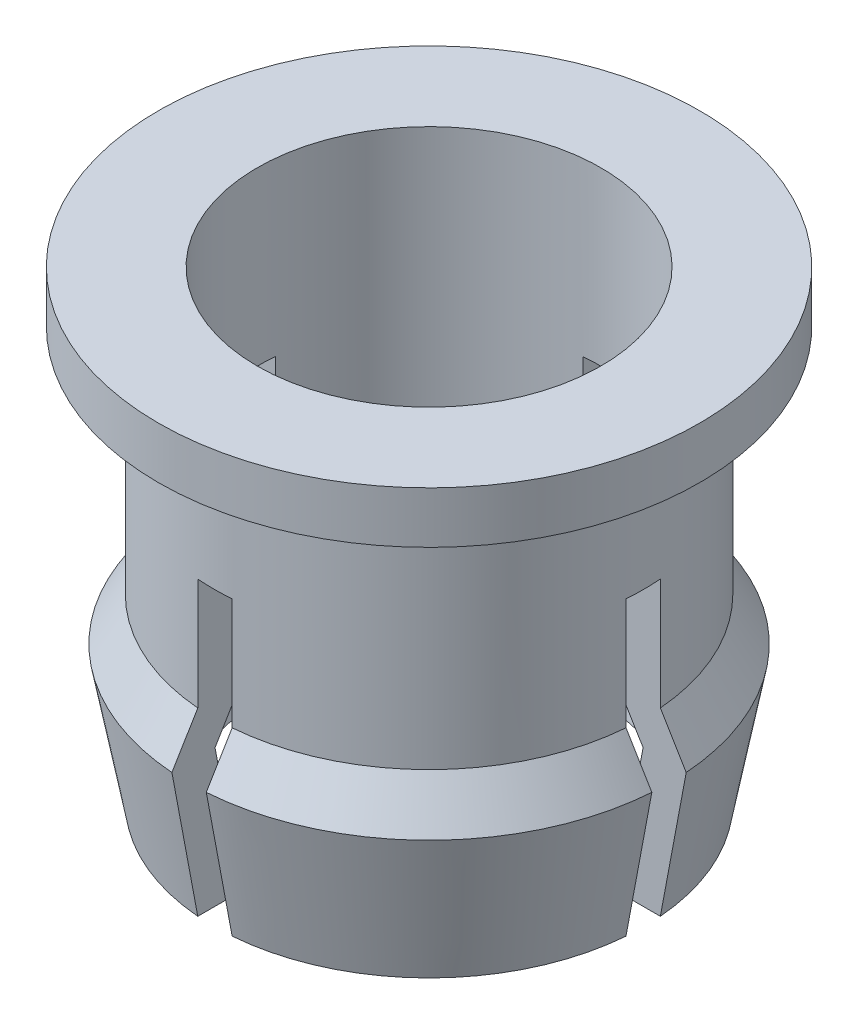
from build123d import *

# Parameters (mm, degrees)
SKETCH1_R          = 4.0005
SKETCH1_R_2        = 2.54
EXTRUDE1_DEPTH     = 0.762
SKETCH2_R          = 3.175
SKETCH2_R_2        = 2.54
EXTRUDE2_DEPTH     = 3.429
CUT_EXTRUDE1_DEPTH = 5.318


with BuildPart() as part:
    # Sketch1 → Extrude1 (new body)
    with BuildSketch(Plane(origin=(0, 0, 0), x_dir=(1, 0, 0), z_dir=(0, 1, 0))):
        Circle(SKETCH1_R)
        Circle(SKETCH1_R_2, mode=Mode.SUBTRACT)
    extrude(amount=-EXTRUDE1_DEPTH)

    # Sketch2 → Extrude2 (add)
    with BuildSketch(Plane.XZ.offset(0.762)):
        Circle(SKETCH2_R)
        Circle(SKETCH2_R_2, mode=Mode.SUBTRACT)
    extrude(amount=EXTRUDE2_DEPTH)

    # Sketch3 → Revolve1 (revolve)
    with BuildSketch(Plane(origin=(0, 0, 0), x_dir=(0, 0, -1), z_dir=(1, 0, 0))):
        Polygon((-3.175, -4.191), (-2.54, -4.191), (-2.921, -4.826), (-2.54, -6.858), (-3.175, -6.858), (-3.556, -4.826), align=None)
    revolve(axis=Axis((0, 1.21490396, 0), (0, -1, 0)))

    # Sketch5 → Cut-Extrude1 (cut, through all)
    with BuildSketch(Plane.XZ.offset(2.54)):
        Polygon((-0.254, 0.254), (-4.064, 0.254), (-4.064, -0.254), (-0.254, -0.254), (-0.254, -4.064), (0.254, -4.064), (0.254, -0.254), (4.064, -0.254), (4.064, 0.254), (0.254, 0.254), (0.254, 4.064), (-0.254, 4.064), align=None)
    extrude(amount=CUT_EXTRUDE1_DEPTH, mode=Mode.SUBTRACT)


solid = part.part
